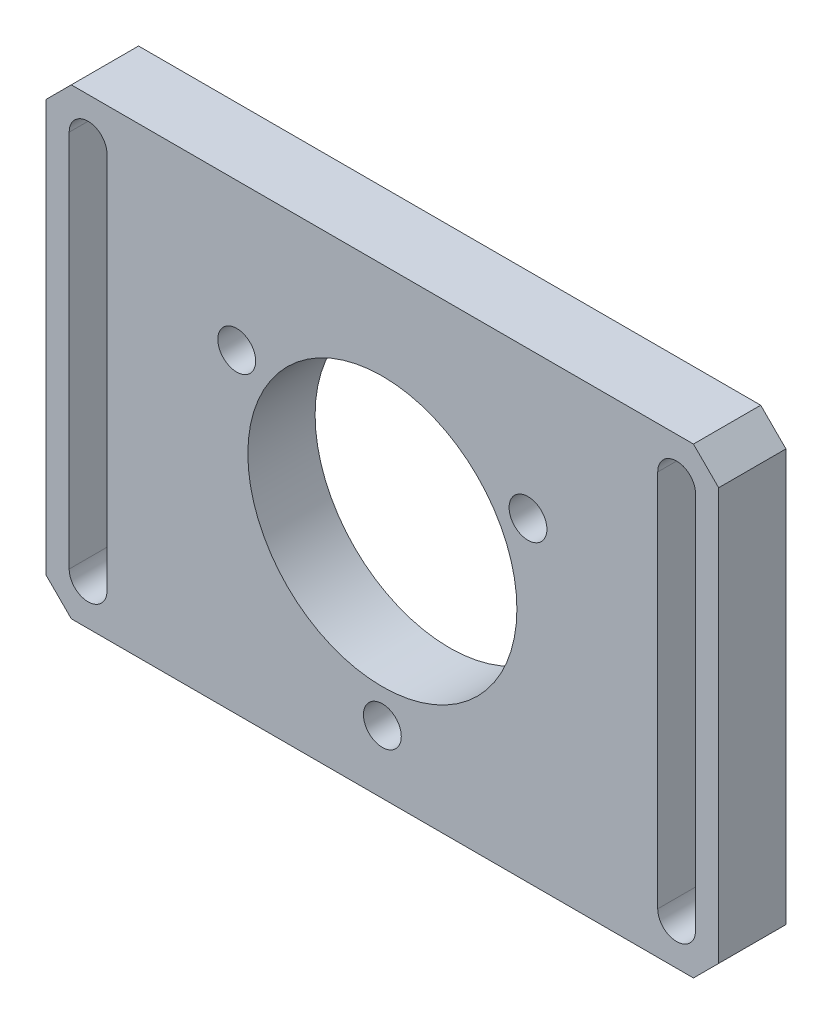
from build123d import *

# Parameters (mm, degrees)
SKETCH1_W           = 80
SKETCH1_H           = 55
SKETCH1_R           = 16
BOSS_EXTRUDE1_DEPTH = 8
SKETCH2_R           = 2.25
CUT_EXTRUDE1_DEPTH  = 8
CIRPATTERN1_COUNT   = 3
CHAMFER1_SIZE       = 3


with BuildPart() as part:
    # Sketch1 → Boss-Extrude1 (new body)
    with BuildSketch(Plane.XY):
        with Locations((10.344708022, -11.227107004)):
            Rectangle(SKETCH1_W, SKETCH1_H)
        with Locations((10.344708022, -11.227107004)):
            Circle(SKETCH1_R, mode=Mode.SUBTRACT)
        with BuildLine():
            Line((-26.905291978, 11.272892996), (-26.905291978, -33.727107004))
            ThreePointArc((-26.905291978, -33.727107004), (-24.655291978, -35.977107004), (-22.405291978, -33.727107004))
            Line((-22.405291978, -33.727107004), (-22.405291978, 11.272892996))
            ThreePointArc((-22.405291978, 11.272892996), (-24.655291978, 13.522892996), (-26.905291978, 11.272892996))
        make_face(mode=Mode.SUBTRACT)
        with BuildLine():
            Line((43.094708022, 11.272892996), (43.094708022, -33.727107004))
            ThreePointArc((43.094708022, -33.727107004), (45.344708022, -35.977107004), (47.594708022, -33.727107004))
            Line((47.594708022, -33.727107004), (47.594708022, 11.272892996))
            ThreePointArc((47.594708022, 11.272892996), (45.344708022, 13.522892996), (43.094708022, 11.272892996))
        make_face(mode=Mode.SUBTRACT)
    extrude(amount=-BOSS_EXTRUDE1_DEPTH)

    # Sketch2 → Cut-Extrude1 (cut)
    with BuildSketch(Plane.XY):
        with Locations((10.344708022, -31.227107004)):
            Circle(SKETCH2_R)
    cut_extrude1 = extrude(amount=-CUT_EXTRUDE1_DEPTH, mode=Mode.SUBTRACT)

    # CirPattern1: Cut-Extrude1 ×3 about axis
    cirpattern1_axis = Axis((10.344708022, -11.227107004, 0), (0, 0, 1))
    for i in range(1, CIRPATTERN1_COUNT):
        add(cut_extrude1.rotate(cirpattern1_axis, i * 360 / CIRPATTERN1_COUNT), mode=Mode.SUBTRACT)

    # Chamfer1
    chamfer1_edges = [part.edges().sort_by_distance(p)[0] for p in [
        (-29.655291978, 16.272892996, -4),
        (50.344708022, 16.272892996, -4),
        (50.344708022, -38.727107004, -4),
        (-29.655291978, -38.727107004, -4),
    ]]
    chamfer(chamfer1_edges, length=CHAMFER1_SIZE)


solid = part.part
